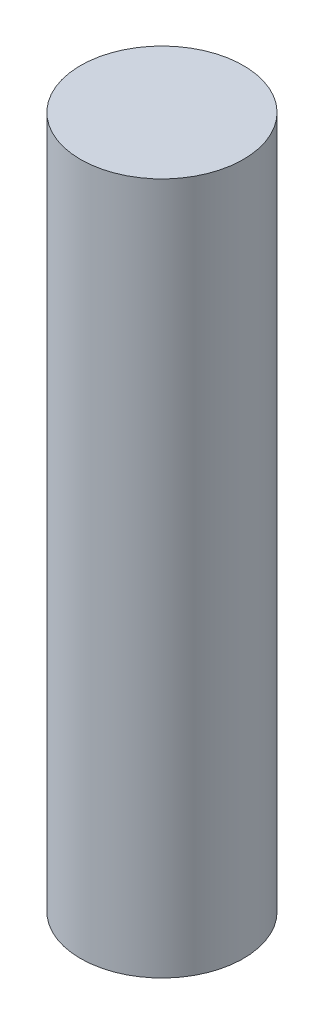
from build123d import *

# Parameters (mm, degrees)
SKETCH_1_R          = 10
EXTRUDE_1_DEPTH     = 85
SKETCH_2_R          = 2
CUT_EXTRUDE_1_DEPTH = 60


with BuildPart() as part:
    # Эскиз1 → Бобышка-Вытянуть1 (new body)
    with BuildSketch(Plane(origin=(0, 0, 0), x_dir=(1, 0, 0), z_dir=(0, 1, 0))):
        Circle(SKETCH_1_R)
    extrude(amount=EXTRUDE_1_DEPTH)

    # Эскиз2 → Вырез-Вытянуть1 (cut)
    with BuildSketch(Plane.XZ):
        Circle(SKETCH_2_R)
    extrude(amount=-CUT_EXTRUDE_1_DEPTH, mode=Mode.SUBTRACT)


solid = part.part
